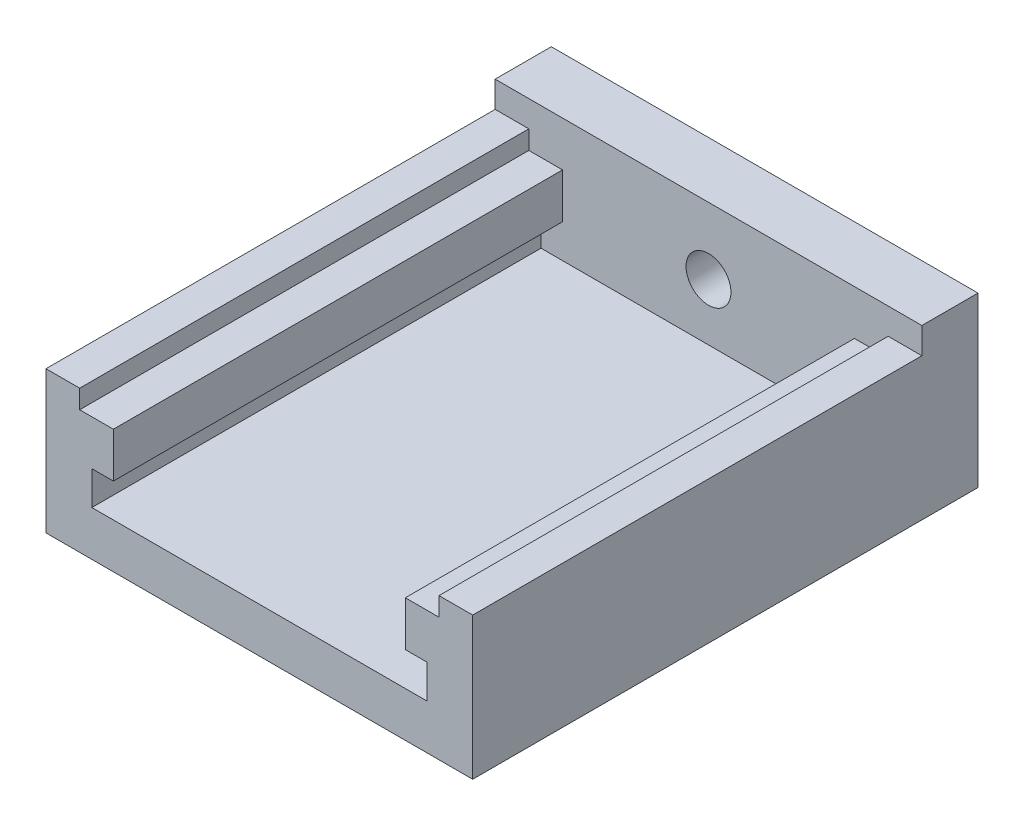
from build123d import *

# Parameters (mm, degrees)
AUFSATZ_LINEAR_AUSTRAGEN1_DEPTH = 40
SKIZZE2_W                       = 38
SKIZZE2_H                       = 15
SKIZZE2_R                       = 2
AUFSATZ_LINEAR_AUSTRAGEN2_DEPTH = 5


with BuildPart() as part:
    # Skizze1 → Aufsatz-Linear austragen1 (new body)
    with BuildSketch(Plane.XY):
        Polygon((-16, 1.942512926), (-13, 1.942512926), (-13, -2.057487074), (-14.916666667, -2.057487074), (-14.916666667, -5.057487074), (14.916666667, -5.057487074), (14.916666667, -2.057487074), (13, -2.057487074), (13, 1.942512926), (16, 1.942512926), (16, 3.609179593), (19, 3.609179593), (19, -9.057487074), (-19, -9.057487074), (-19, 3.609179593), (-16, 3.609179593), align=None)
    extrude(amount=AUFSATZ_LINEAR_AUSTRAGEN1_DEPTH)

    # Skizze2 → Aufsatz-Linear austragen2 (add)
    with BuildSketch(Plane(origin=(0, 0, 0), x_dir=(-1, 0, 0), z_dir=(0, 0, -1))):
        with Locations((0, -1.557487074)):
            Rectangle(SKIZZE2_W, SKIZZE2_H)
        Circle(SKIZZE2_R, mode=Mode.SUBTRACT)
    extrude(amount=AUFSATZ_LINEAR_AUSTRAGEN2_DEPTH)


solid = part.part
